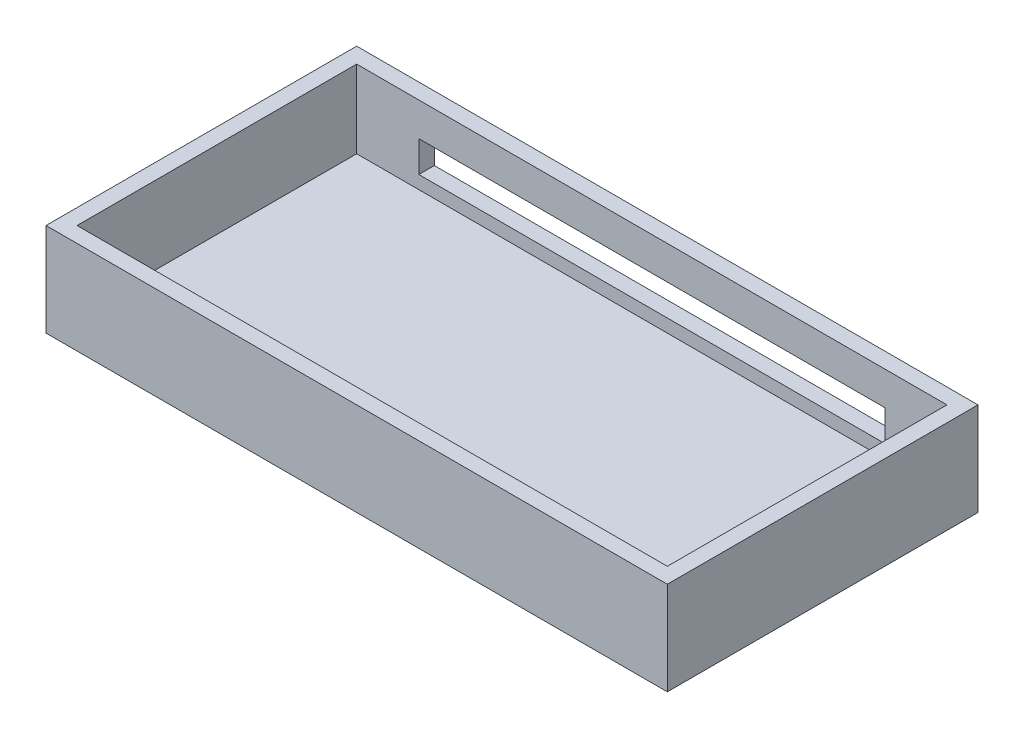
from build123d import *

# Parameters (mm, degrees)
SKETCH2_W           = 200
SKETCH2_H           = 100
BOSS_EXTRUDE1_DEPTH = 30
SHELL1_T            = -5
SKETCH3_W           = 150
SKETCH3_H           = 10
CUT_EXTRUDE1_DEPTH  = 10


with BuildPart() as part:
    # Sketch2 → Boss-Extrude1 (new body)
    with BuildSketch(Plane(origin=(0, 0, 0), x_dir=(1, 0, 0), z_dir=(0, 1, 0))):
        Rectangle(SKETCH2_W, SKETCH2_H)
    extrude(amount=BOSS_EXTRUDE1_DEPTH)

    # Shell1
    shell1_openings = [part.faces().sort_by_distance(p)[0] for p in [
        (0, 30, 0),
    ]]
    offset(amount=SHELL1_T, openings=shell1_openings, kind=Kind.INTERSECTION)

    # Sketch3 → Cut-Extrude1 (cut)
    with BuildSketch(Plane.XY.offset(-45)):
        with Locations((0, 14.223574028)):
            Rectangle(SKETCH3_W, SKETCH3_H)
    extrude(amount=-CUT_EXTRUDE1_DEPTH, mode=Mode.SUBTRACT)


solid = part.part
